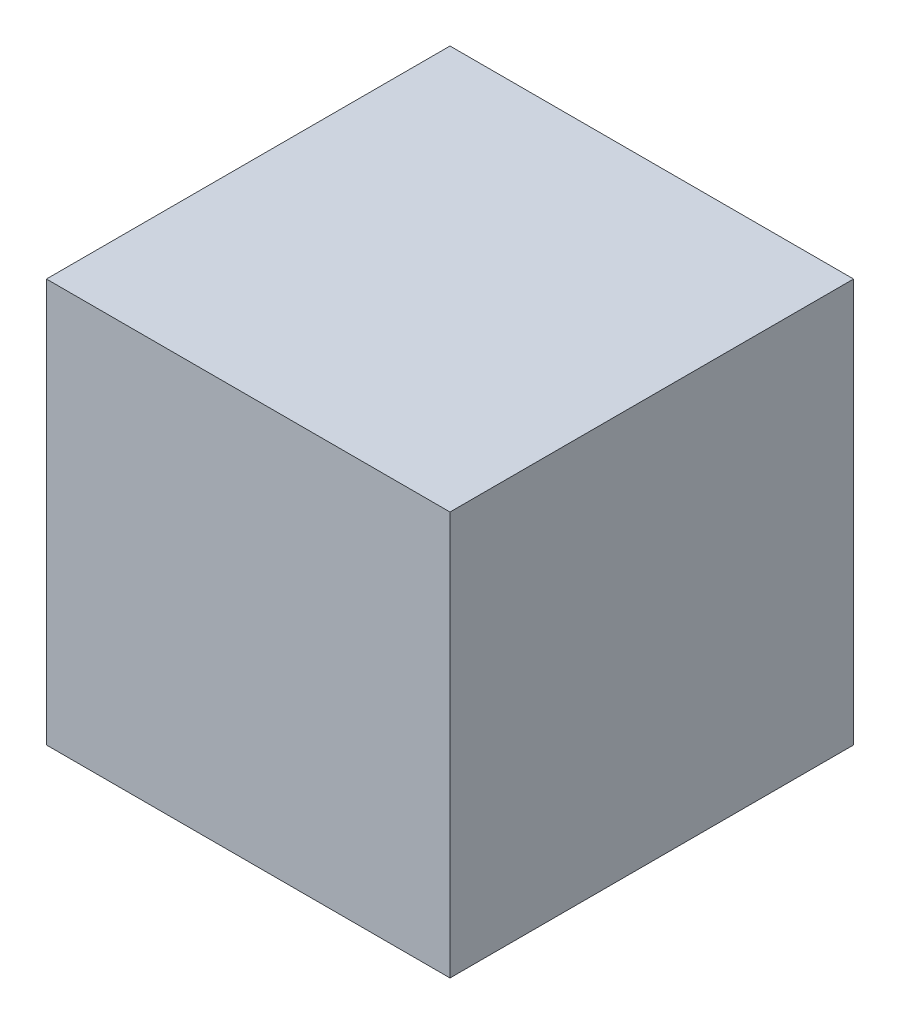
from build123d import *

# Parameters (mm, degrees)
SKETCH1_W           = 139.7
SKETCH1_H           = 139.7
BOSS_EXTRUDE1_DEPTH = 139.7


with BuildPart() as part:
    # Sketch1 → Boss-Extrude1 (new body)
    with BuildSketch(Plane(origin=(0, 0, 0), x_dir=(1, 0, 0), z_dir=(0, 1, 0))):
        with Locations((-69.85, 69.85)):
            Rectangle(SKETCH1_W, SKETCH1_H)
    extrude(amount=BOSS_EXTRUDE1_DEPTH)


solid = part.part
